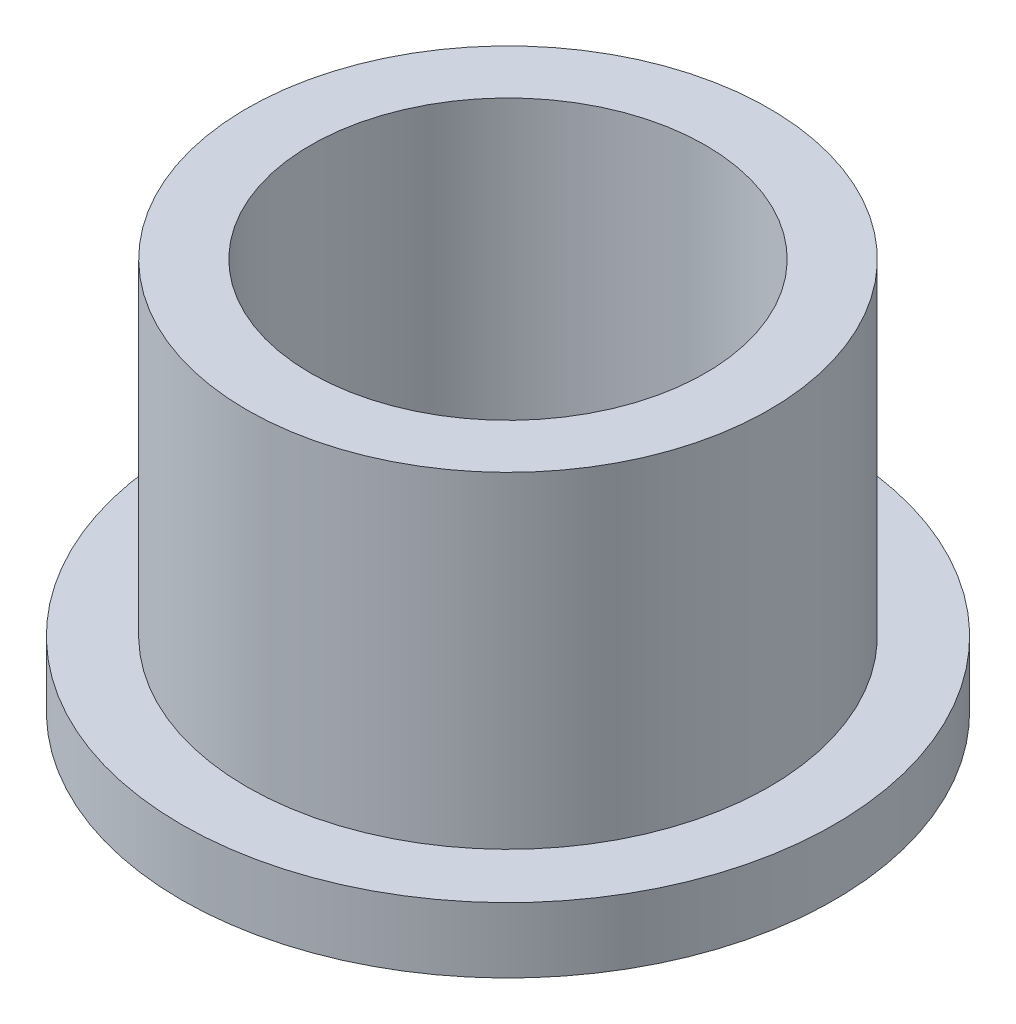
from build123d import *

# Parameters (mm, degrees)
SKETCH2_R           = 6.35
SKETCH2_R_2         = 4.8006
BOSS_EXTRUDE1_DEPTH = 9.525
SKETCH3_R           = 7.9375
SKETCH3_R_2         = 6.35
BOSS_EXTRUDE2_DEPTH = 1.5875


with BuildPart() as part:
    # Sketch2 → Boss-Extrude1 (new body)
    with BuildSketch(Plane(origin=(0, 0, 0), x_dir=(1, 0, 0), z_dir=(0, 1, 0))):
        Circle(SKETCH2_R)
        Circle(SKETCH2_R_2, mode=Mode.SUBTRACT)
    extrude(amount=BOSS_EXTRUDE1_DEPTH)

    # Sketch3 → Boss-Extrude2 (add)
    with BuildSketch(Plane(origin=(0, 0, 0), x_dir=(1, 0, 0), z_dir=(0, 1, 0))):
        Circle(SKETCH3_R)
        Circle(SKETCH3_R_2, mode=Mode.SUBTRACT)
    extrude(amount=BOSS_EXTRUDE2_DEPTH)


solid = part.part
